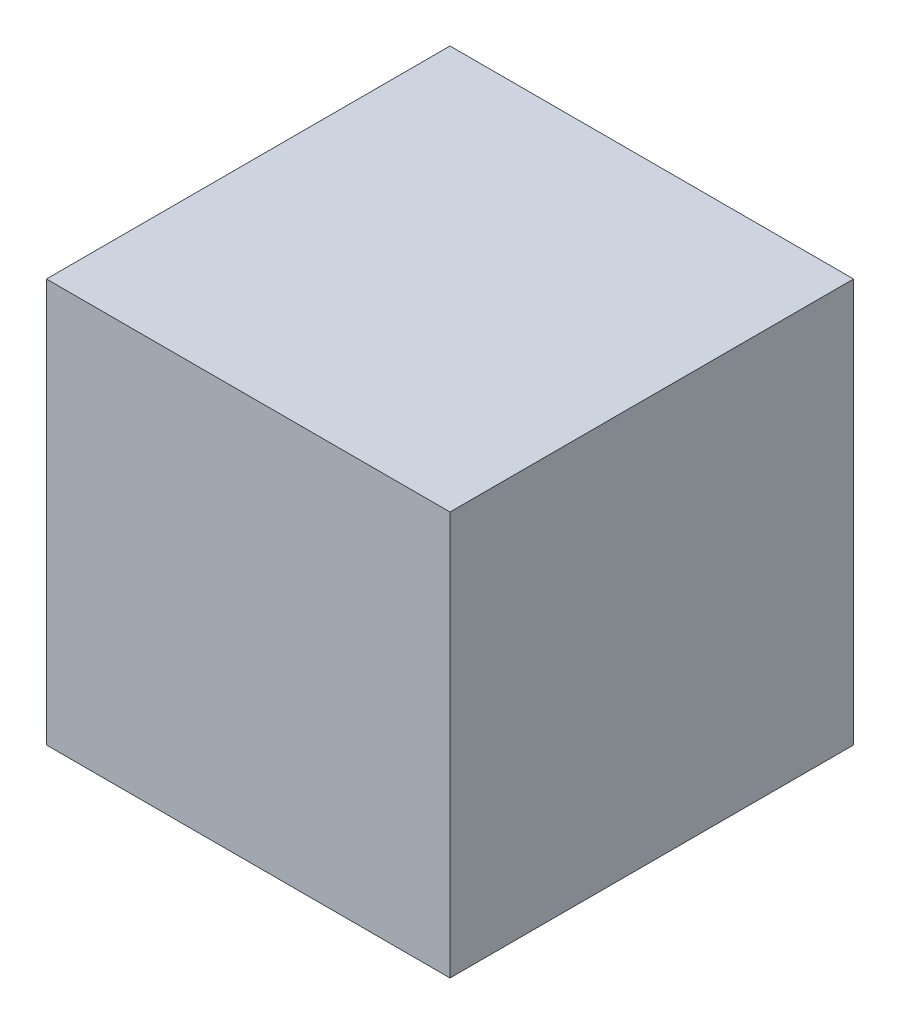
from build123d import *

# Parameters (mm, degrees)
SKETCH1_W           = 304.8
SKETCH1_H           = 304.8
BOSS_EXTRUDE1_DEPTH = 304.8


with BuildPart() as part:
    # Sketch1 → Boss-Extrude1 (new body)
    with BuildSketch(Plane.XY):
        Rectangle(SKETCH1_W, SKETCH1_H)
    extrude(amount=-BOSS_EXTRUDE1_DEPTH)


solid = part.part
